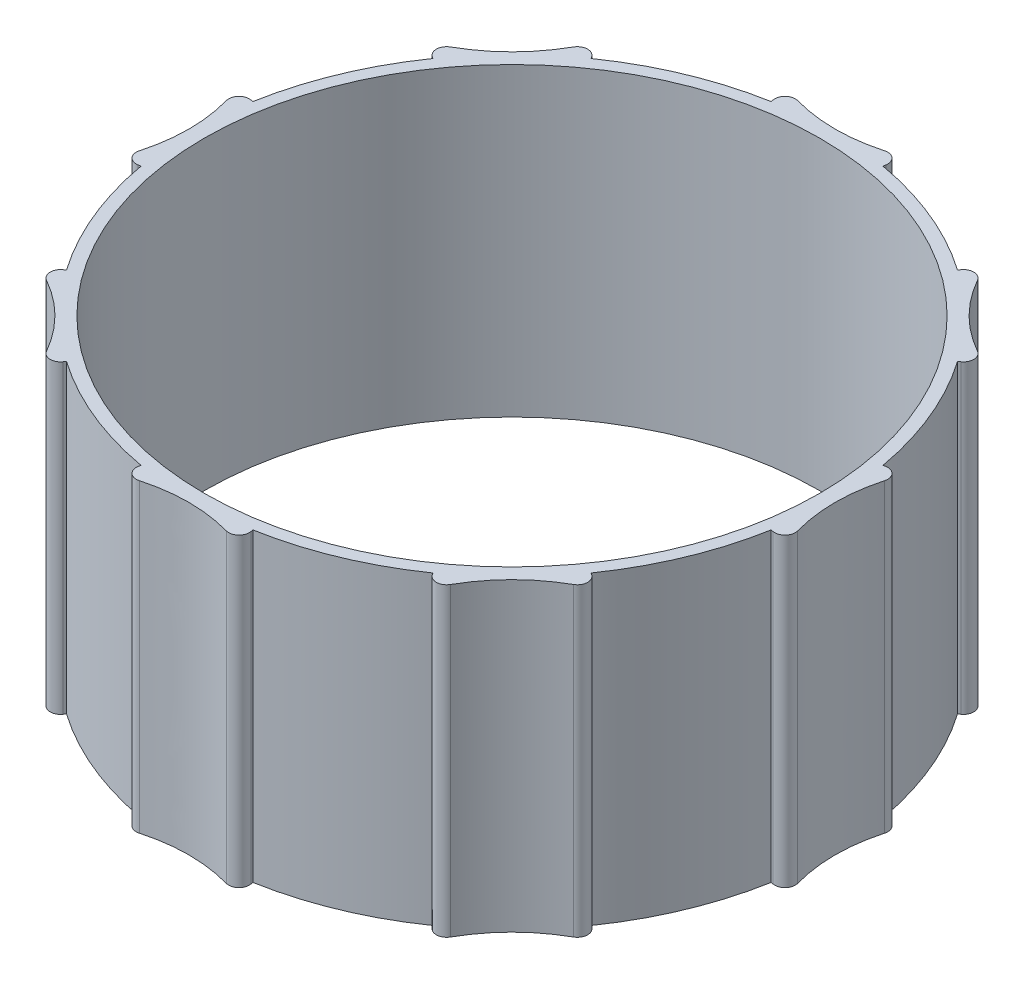
from build123d import *

# Parameters (mm, degrees)
SKETCH3_R           = 37.8587
BOSS_EXTRUDE1_DEPTH = 37.5666


with BuildPart() as part:
    # Sketch3 → Boss-Extrude1 (new body)
    with BuildSketch(Plane(origin=(0, -37.5666, 0), x_dir=(1, 0, 0), z_dir=(0, 1, 0))):
        with BuildLine():
            Line((22.710713351, 32.518210948), (22.542535263, 32.277406051))
            ThreePointArc((22.542535263, 32.277406051), (15.06624702, 36.373135768), (6.883594535, 38.763551242))
            Line((6.883594535, 38.763551242), (6.934949387, 39.052745559))
            ThreePointArc((6.934949387, 39.052745559), (6.539953295, 40.213477214), (5.347634612, 40.499302411))
            add(Edge.make_bspline(
                [(5.347634612, 40.499302411), (0, 39.028097589), (-5.347634612, 40.499302411)],
                knots=[0.133971893, 0.133971893, 0.133971893, 0.866028107, 0.866028107, 0.866028107], degree=2))
            ThreePointArc((-5.347634612, 40.499302411), (-6.539953295, 40.213477214), (-6.934949387, 39.052745559))
            Line((-6.934949387, 39.052745559), (-6.883594478, 38.763550918))
            ThreePointArc((-6.883594478, 38.763550918), (-15.06624685, 36.373135059), (-22.542534901, 32.277404991))
            Line((-22.542534901, 32.277404991), (-22.7107128, 32.518209618))
            ThreePointArc((-22.7107128, 32.518209618), (-23.810778439, 33.059666427), (-24.855984001, 32.418678735))
            add(Edge.make_bspline(
                [(-24.855984001, 32.418678735), (-27.597033743, 27.597031182), (-32.418681395, 24.855981341)],
                knots=[0.133971893, 0.133971893, 0.133971893, 0.866028107, 0.866028107, 0.866028107], degree=2))
            ThreePointArc((-32.418681395, 24.855981341), (-33.059669087, 23.810775779), (-32.518212278, 22.71071014))
            Line((-32.518212278, 22.71071014), (-32.277407381, 22.542532053))
            ThreePointArc((-32.277407381, 22.542532053), (-36.373137098, 15.066243809), (-38.763552571, 6.883591325))
            Line((-38.763552571, 6.883591325), (-39.052746889, 6.934946176))
            ThreePointArc((-39.052746889, 6.934946176), (-40.213478544, 6.539950084), (-40.499303741, 5.347631401))
            add(Edge.make_bspline(
                [(-40.499303741, 5.347631401), (-39.028096259, -3.092e-06), (-40.499303741, -5.347637823)],
                knots=[0.133971893, 0.133971893, 0.133971893, 0.866028107, 0.866028107, 0.866028107], degree=2))
            ThreePointArc((-40.499303741, -5.347637823), (-40.213478544, -6.539956506), (-39.052746889, -6.934952598))
            Line((-39.052746889, -6.934952598), (-38.763552248, -6.883597689))
            ThreePointArc((-38.763552248, -6.883597689), (-36.373136389, -15.066250061), (-32.277406321, -22.542538112))
            Line((-32.277406321, -22.542538112), (-32.518210948, -22.710716011))
            ThreePointArc((-32.518210948, -22.710716011), (-33.059667757, -23.81078165), (-32.418680065, -24.855987212))
            add(Edge.make_bspline(
                [(-32.418680065, -24.855987212), (-27.597028006, -27.597032378), (-24.855982671, -32.418684606)],
                knots=[0.133971893, 0.133971893, 0.133971893, 0.866028107, 0.866028107, 0.866028107], degree=2))
            ThreePointArc((-24.855982671, -32.418684606), (-23.810777109, -33.059672297), (-22.71071147, -32.518215489))
            Line((-22.71071147, -32.518215489), (-22.542533383, -32.277410592))
            ThreePointArc((-22.542533383, -32.277410592), (-15.066245139, -36.373140308), (-6.883592655, -38.763555782))
            Line((-6.883592655, -38.763555782), (-6.934947506, -39.0527501))
            ThreePointArc((-6.934947506, -39.0527501), (-6.539951414, -40.213481755), (-5.347632731, -40.499306952))
            add(Edge.make_bspline(
                [(-5.347632731, -40.499306952), (1.811e-06, -39.028093048), (5.347636493, -40.499306952)],
                knots=[0.133971893, 0.133971893, 0.133971893, 0.866028107, 0.866028107, 0.866028107], degree=2))
            ThreePointArc((5.347636493, -40.499306952), (6.539955176, -40.213481755), (6.934951268, -39.0527501))
            Line((6.934951268, -39.0527501), (6.883596359, -38.763555459))
            ThreePointArc((6.883596359, -38.763555459), (15.066248731, -36.3731396), (22.542536782, -32.277409531))
            Line((22.542536782, -32.277409531), (22.710714681, -32.518214159))
            ThreePointArc((22.710714681, -32.518214159), (23.81078032, -33.059670967), (24.855985882, -32.418683276))
            add(Edge.make_bspline(
                [(24.855985882, -32.418683276), (27.597029251, -27.597029251), (32.418683276, -24.855985882)],
                knots=[0.133971893, 0.133971893, 0.133971893, 0.866028107, 0.866028107, 0.866028107], degree=2))
            ThreePointArc((32.418683276, -24.855985882), (33.059670967, -23.81078032), (32.518214159, -22.710714681))
            Line((32.518214159, -22.710714681), (32.277409262, -22.542536593))
            ThreePointArc((32.277409262, -22.542536593), (36.373138978, -15.06624835), (38.763554452, -6.883595865))
            Line((38.763554452, -6.883595865), (39.05274877, -6.934950717))
            ThreePointArc((39.05274877, -6.934950717), (40.213480425, -6.539954625), (40.499305622, -5.347635942))
            add(Edge.make_bspline(
                [(40.499305622, -5.347635942), (39.028094378, -1.281e-06), (40.499305622, 5.347633282)],
                knots=[0.133971893, 0.133971893, 0.133971893, 0.866028107, 0.866028107, 0.866028107], degree=2))
            ThreePointArc((40.499305622, 5.347633282), (40.213480425, 6.539951965), (39.05274877, 6.934948057))
            Line((39.05274877, 6.934948057), (38.763554129, 6.883593148))
            ThreePointArc((38.763554129, 6.883593148), (36.37313827, 15.06624552), (32.277408202, 22.542533571))
            Line((32.277408202, 22.542533571), (32.518212829, 22.71071147))
            ThreePointArc((32.518212829, 22.71071147), (33.059669637, 23.810777109), (32.418681946, 24.855982671))
            add(Edge.make_bspline(
                [(32.418681946, 24.855982671), (27.597032427, 27.597030616), (24.855984552, 32.418680065)],
                knots=[0.133971893, 0.133971893, 0.133971893, 0.866028107, 0.866028107, 0.866028107], degree=2))
            ThreePointArc((24.855984552, 32.418680065), (23.81077899, 33.059667757), (22.710713351, 32.518210948))
        make_face()
        with Locations(Location((0, 0, 0), (0, 0, 270))):
            Circle(SKETCH3_R, mode=Mode.SUBTRACT)
    extrude(amount=BOSS_EXTRUDE1_DEPTH)


solid = part.part
